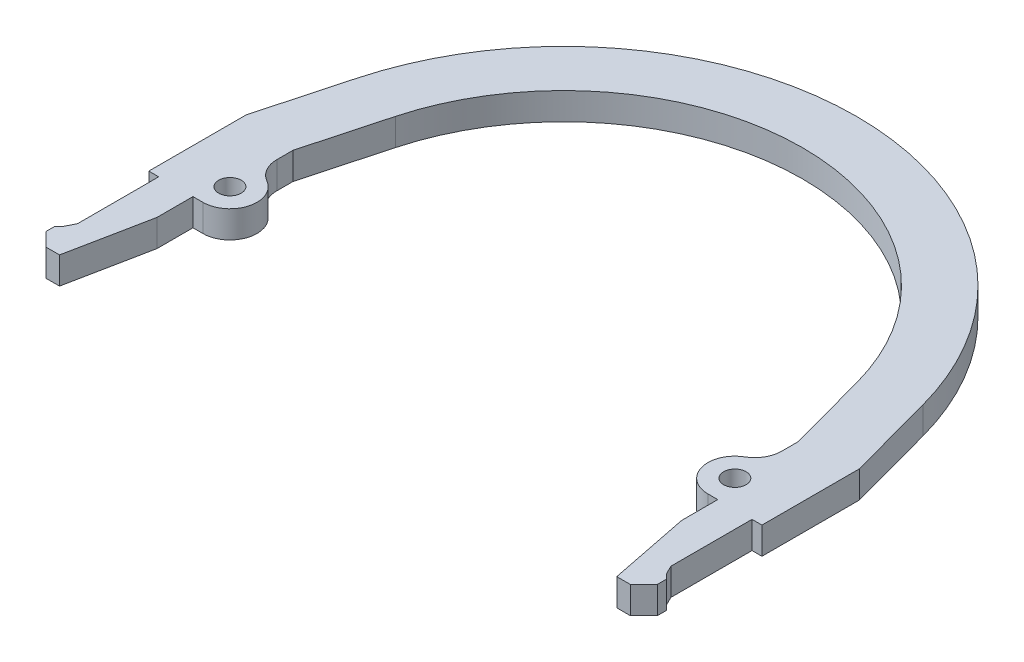
from build123d import *

# Parameters (mm, degrees)
BOSS_EXTRUDE1_DEPTH = 3
BOSS_EXTRUDE2_DEPTH = 3
FILLET1_R           = 3
SKETCH4_R           = 1.25
CUT_EXTRUDE1_DEPTH  = 4


with BuildPart() as part:
    # Sketch1 → Boss-Extrude1 (new body)
    with BuildSketch(Plane(origin=(0, 0, 0), x_dir=(1, 0, 0), z_dir=(0, 1, 0))):
        with BuildLine():
            Line((29.1, -16), (29.1, -12))
            Line((29.1, -12), (28, -12))
            Line((28, -12), (28, -2))
            Line((28, -2), (25.57587166, 6.937203242))
            ThreePointArc((25.57587166, 6.937203242), (16.099908604, 21.048585296), (0, 26.5))
            Line((0, 26.5), (0, 32.5))
            ThreePointArc((0, 32.5), (19.745170929, 25.814302721), (31.366635055, 8.507890769))
            Line((31.366635055, 8.507890769), (34, -1.200719678))
            Line((34, -1.200719678), (34, -12))
            Line((34, -12), (32.9, -12))
            Line((32.9, -12), (32.9, -21))
            Line((32.9, -21), (33.4, -22))
            Line((33.4, -22), (33.9, -22.5))
            Line((33.9, -22.5), (33.9, -23.5))
            Line((33.9, -23.5), (32.4, -25))
            Line((32.4, -25), (30.9, -25))
            Line((30.9, -25), (29.1, -16))
        make_face()
    extrude(amount=BOSS_EXTRUDE1_DEPTH)

    # Sketch3 → Boss-Extrude2 (add)
    with BuildSketch(Plane(origin=(0, 0, 0), x_dir=(1, 0, 0), z_dir=(0, 1, 0))):
        with BuildLine():
            Line((28, -6), (28, -12))
            ThreePointArc((28, -12), (25, -9), (28, -6))
        make_face()
    extrude(amount=BOSS_EXTRUDE2_DEPTH)

    # Fillet1
    fillet1_edges = [part.edges().sort_by_distance(p)[0] for p in [
        (28, 1.5, 6),
    ]]
    fillet(fillet1_edges, radius=FILLET1_R)

    # Sketch4 → Cut-Extrude1 (cut, through all)
    with BuildSketch(Plane(origin=(0, 3, 0), x_dir=(1, 0, 0), z_dir=(0, 1, 0))):
        with Locations((28, -9)):
            Circle(SKETCH4_R)
    extrude(amount=-CUT_EXTRUDE1_DEPTH, mode=Mode.SUBTRACT)

    # Mirror1: part across plane


with BuildPart() as part_1:
    add(part.part)
    add(part.part.mirror(Plane(origin=(0, 0, 0), x_dir=(0, 0, 1), z_dir=(1, 0, 0))))


solid = part_1.part
